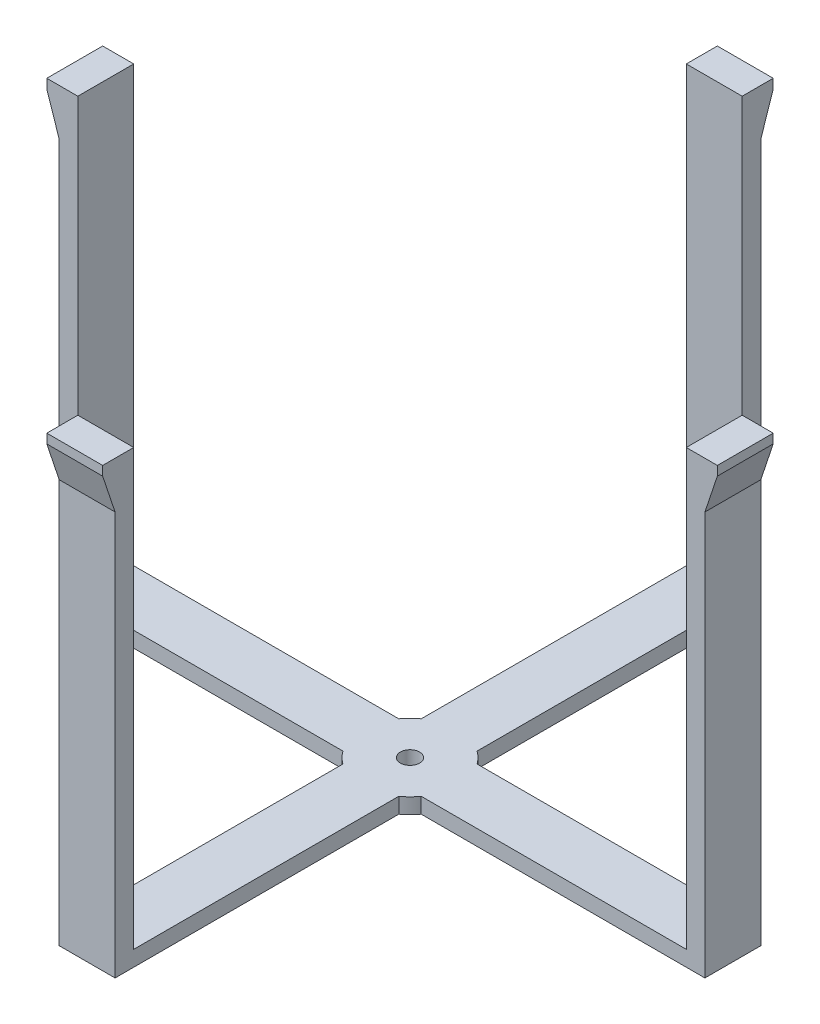
from build123d import *

# Parameters (mm, degrees)
BOSS_EXTRUDE3_DEPTH = 6.35
SKETCH9_R           = 3.937
CUT_EXTRUDE4_DEPTH  = 127
SKETCH8_W           = 22.86
SKETCH8_H           = 7.62
BOSS_EXTRUDE4_DEPTH = 177.8
CIRPATTERN1_COUNT   = 4
BOSS_EXTRUDE6_DEPTH = 22.86
CIRPATTERN2_COUNT   = 4


with BuildPart() as part:
    # Sketch5 → Boss-Extrude3 (new body)
    with BuildSketch(Plane(origin=(0, 0, 0), x_dir=(1, 0, 0), z_dir=(0, 1, 0))):
        with BuildLine():
            Line((-16.026675419, 11.43), (-132.08, 11.43))
            Line((-132.08, 11.43), (-132.08, -11.43))
            Line((-132.08, -11.43), (-16.026675419, -11.43))
            ThreePointArc((-16.026675419, -11.43), (-13.919396988, -13.919396988), (-11.43, -16.026675419))
            Line((-11.43, -16.026675419), (-11.43, -132.08))
            Line((-11.43, -132.08), (11.43, -132.08))
            Line((11.43, -132.08), (11.43, -16.026675419))
            ThreePointArc((11.43, -16.026675419), (13.919396988, -13.919396988), (16.026675419, -11.43))
            Line((16.026675419, -11.43), (132.08, -11.43))
            Line((132.08, -11.43), (132.08, 11.43))
            Line((132.08, 11.43), (16.026675419, 11.43))
            ThreePointArc((16.026675419, 11.43), (13.919396988, 13.919396988), (11.43, 16.026675419))
            Line((11.43, 16.026675419), (11.43, 132.08))
            Line((11.43, 132.08), (-11.43, 132.08))
            Line((-11.43, 132.08), (-11.43, 16.026675419))
            ThreePointArc((-11.43, 16.026675419), (-13.919396988, 13.919396988), (-16.026675419, 11.43))
        make_face()
    extrude(amount=BOSS_EXTRUDE3_DEPTH)

    # Sketch9 → Cut-Extrude4 (cut)
    with BuildSketch(Plane(origin=(0, 6.35, 0), x_dir=(1, 0, 0), z_dir=(0, 1, 0))):
        Circle(SKETCH9_R)
    extrude(amount=-CUT_EXTRUDE4_DEPTH, mode=Mode.SUBTRACT)

    # Sketch8 → Boss-Extrude4 (add)
    with BuildSketch(Plane(origin=(0, 6.35, 0), x_dir=(1, 0, 0), z_dir=(0, 1, 0))):
        with Locations((0, -128.27)):
            Rectangle(SKETCH8_W, SKETCH8_H)
    boss_extrude4 = extrude(amount=BOSS_EXTRUDE4_DEPTH)

    # CirPattern1: Boss-Extrude4 ×4 about axis
    cirpattern1_axis = Axis((0, 0, 0), (0, 1, 0))
    for i in range(1, CIRPATTERN1_COUNT):
        add(boss_extrude4.rotate(cirpattern1_axis, i * 360 / CIRPATTERN1_COUNT))

    # Sketch13 → Boss-Extrude6 (add)
    with BuildSketch(Plane.XY.offset(11.43)):
        Polygon((-132.08, 184.15), (-137.16, 184.15), (-137.16, 180.34), (-132.08, 165.1), align=None)
    boss_extrude6 = extrude(amount=-BOSS_EXTRUDE6_DEPTH)

    # CirPattern2: Boss-Extrude6 ×4 about axis
    cirpattern2_axis = Axis((0, 0, 0), (0, 1, 0))
    for i in range(1, CIRPATTERN2_COUNT):
        add(boss_extrude6.rotate(cirpattern2_axis, i * 360 / CIRPATTERN2_COUNT))


solid = part.part
